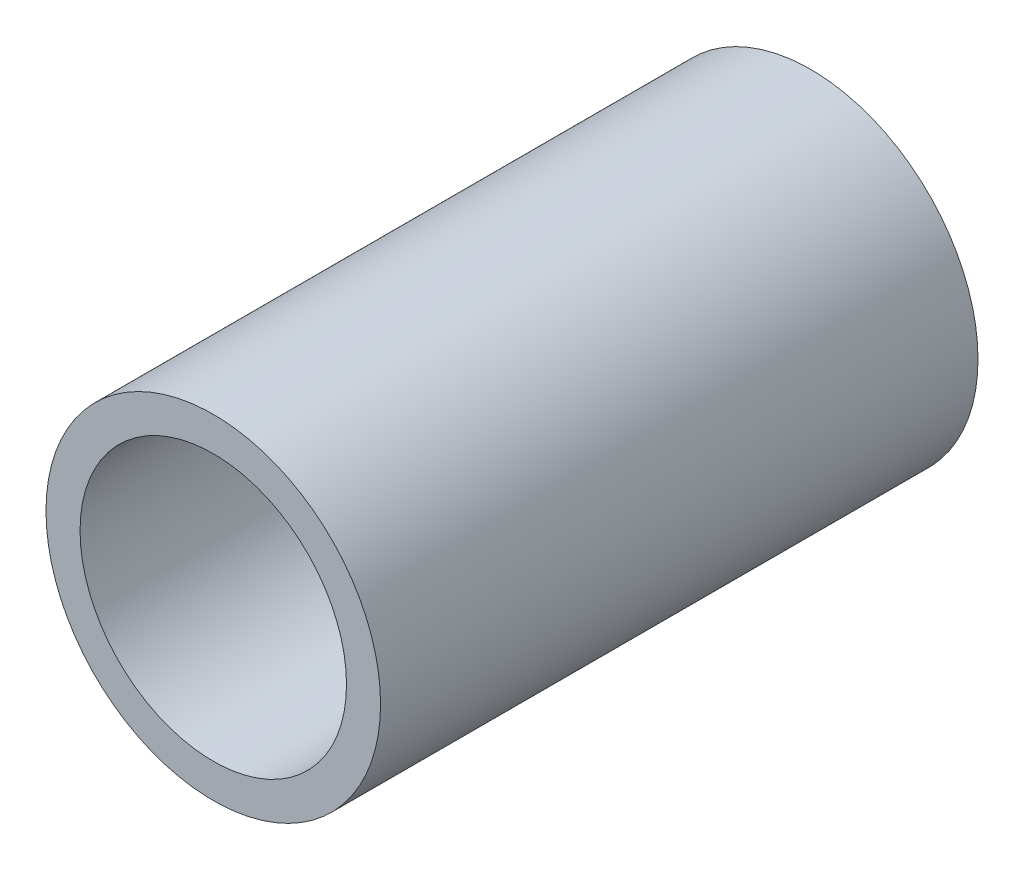
from build123d import *

# Parameters (mm, degrees)
ESBO_O1_R                = 14
ESBO_O1_R_2              = 11.15
RESSALTO_EXTRUS_O1_DEPTH = 50


with BuildPart() as part:
    # Esboço1 → Ressalto-extrusão1 (new body)
    with BuildSketch(Plane.XY):
        with Locations((2.253649096, 0)):
            Circle(ESBO_O1_R)
        with Locations((2.253649096, 0)):
            Circle(ESBO_O1_R_2, mode=Mode.SUBTRACT)
    extrude(amount=RESSALTO_EXTRUS_O1_DEPTH)


solid = part.part
